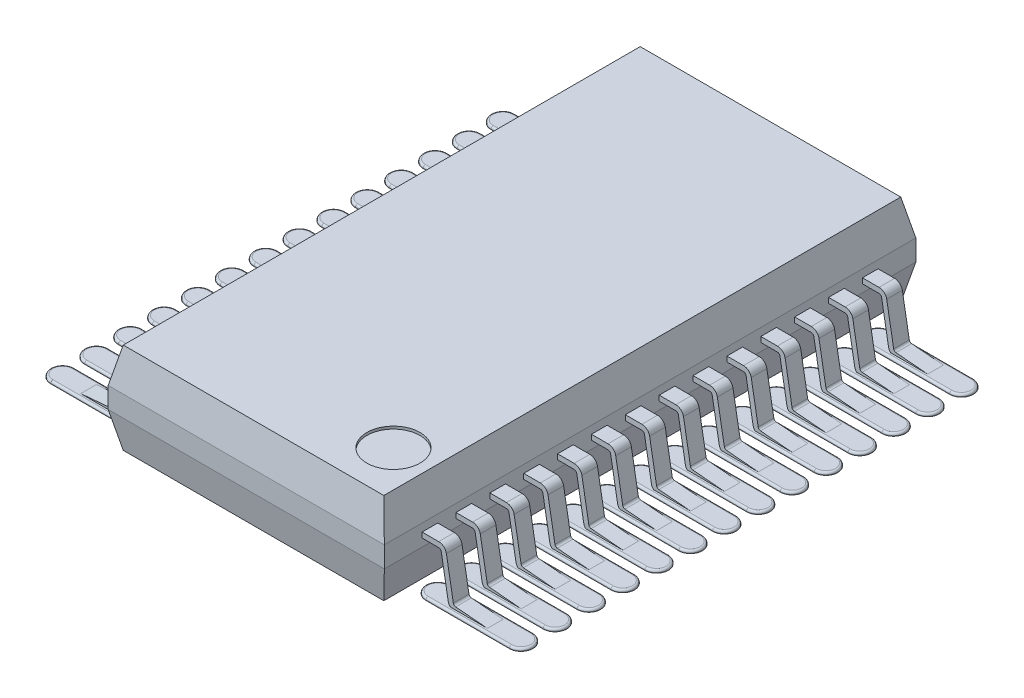
from build123d import *

# Parameters (mm, degrees)
BOSS_EXTRUDE1_DEPTH     = 5.1
CUT_EXTRUDE2_DEPTH      = 7.037797612
CUT_EXTRUDE2_DEPTH_BACK = 7.037797612
EXTRUDE_THIN1_DEPTH     = 0.15
BOSS_EXTRUDE2_DEPTH     = 0.05
FILLET1_R               = 0.04
LPATTERN1_COUNT         = 14
LPATTERN1_PITCH         = 0.65
FILLET1_OF_LPATTERN1_R  = 0.04
SKETCH3_R               = 0.51
CUT_EXTRUDE1_DEPTH      = 0.05


with BuildPart() as part:
    # Sketch1 → Boss-Extrude1 (new, symmetric)
    with BuildSketch(Plane.XY):
        Polygon((-2.5, 1.85), (2.5, 1.85), (2.65, 1.175), (2.65, 0.775), (2.5, 0.1), (-2.5, 0.1), (-2.65, 0.775), (-2.65, 1.175), align=None)
    extrude(amount=BOSS_EXTRUDE1_DEPTH, both=True)

    # Sketch4 → Cut-Extrude2 (cut, two sides)
    with BuildSketch(Plane(origin=(0, 0, 0), x_dir=(0, 0, -1), z_dir=(1, 0, 0))) as cut_extrude2_sk:
        Polygon((-4.96, 1.85), (-5.1, 1.175), (-5.1, 0.775), (-4.96, 0.1), (-5.16, 0.1), (-5.16, 1.85), align=None)
        Polygon((5.1, 1.175), (4.96, 1.85), (5.16, 1.85), (5.16, 0.1), (4.96, 0.1), (5.1, 0.775), align=None)
    extrude(amount=CUT_EXTRUDE2_DEPTH, mode=Mode.SUBTRACT)
    extrude(cut_extrude2_sk.sketch, amount=-CUT_EXTRUDE2_DEPTH_BACK, mode=Mode.SUBTRACT)

    # Sketch2 → Extrude-Thin1 (add, symmetric)
    with BuildSketch(Plane.XY.offset(4.225)):
        with BuildLine():
            Line((-3.895642213, -0.049809735), (-3.285407414, 0.003578892))
            ThreePointArc((-3.285407414, 0.003578892), (-3.197142244, 0.042416496), (-3.150759612, 0.12696087))
            Line((-3.150759612, 0.12696087), (-3.017329188, 0.883682409))
            ThreePointArc((-3.017329188, 0.883682409), (-3.000228181, 0.913302222), (-2.968088801, 0.925))
            Line((-2.968088801, 0.925), (2.968088801, 0.925))
            ThreePointArc((2.968088801, 0.925), (3.000228181, 0.913302222), (3.017329188, 0.883682409))
            Line((3.017329188, 0.883682409), (3.150759612, 0.12696087))
            ThreePointArc((3.150759612, 0.12696087), (3.197142244, 0.042416496), (3.285407414, 0.003578892))
            Line((3.285407414, 0.003578892), (3.895642213, -0.049809735))
            Line((3.895642213, -0.049809735), (3.904357787, 0.049809735))
            Line((3.904357787, 0.049809735), (3.294122988, 0.103198362))
            ThreePointArc((3.294122988, 0.103198362), (3.264701265, 0.11614423), (3.249240388, 0.144325688))
            Line((3.249240388, 0.144325688), (3.115809963, 0.901047227))
            ThreePointArc((3.115809963, 0.901047227), (3.064506942, 0.989906666), (2.968088801, 1.025))
            Line((2.968088801, 1.025), (-2.968088801, 1.025))
            ThreePointArc((-2.968088801, 1.025), (-3.064506942, 0.989906666), (-3.115809963, 0.901047227))
            Line((-3.115809963, 0.901047227), (-3.249240388, 0.144325688))
            ThreePointArc((-3.249240388, 0.144325688), (-3.264701265, 0.11614423), (-3.294122988, 0.103198362))
            Line((-3.294122988, 0.103198362), (-3.904357787, 0.049809735))
            Line((-3.904357787, 0.049809735), (-3.895642213, -0.049809735))
        make_face()
    extrude_thin1 = extrude(amount=EXTRUDE_THIN1_DEPTH, both=True)

    # Sketch5 → Boss-Extrude2 (add)
    with BuildSketch(Plane(origin=(0, 0, 0), x_dir=(1, 0, 0), z_dir=(0, 1, 0))):
        with BuildLine():
            Line((-2.8, -4.45), (-4.4, -4.45))
            ThreePointArc((-4.4, -4.45), (-4.625, -4.225), (-4.4, -4))
            Line((-4.4, -4), (-2.8, -4))
            ThreePointArc((-2.8, -4), (-2.575, -4.225), (-2.8, -4.45))
        make_face()
        with BuildLine():
            Line((2.8, -4), (4.4, -4))
            ThreePointArc((4.4, -4), (4.625, -4.225), (4.4, -4.45))
            Line((4.4, -4.45), (2.8, -4.45))
            ThreePointArc((2.8, -4.45), (2.575, -4.225), (2.8, -4))
        make_face()
    boss_extrude2 = extrude(amount=BOSS_EXTRUDE2_DEPTH)

    # Fillet1
    fillet1_edges = [part.edges().sort_by_distance(p)[0] for p in [
        (-2.575, 0.05, 4.225),
        (-3.6, 0.05, 4),
        (-4.625, 0.05, 4.225),
        (-3.6, 0.05, 4.45),
        (2.575, 0.05, 4.225),
        (3.6, 0.05, 4.45),
        (4.625, 0.05, 4.225),
        (3.6, 0.05, 4),
    ]]
    fillet(fillet1_edges, radius=FILLET1_R)

    # LPattern1: Extrude-Thin1, Boss-Extrude2 ×14
    with Locations(*[(0, 0, -i * LPATTERN1_PITCH) for i in range(1, LPATTERN1_COUNT)]):
        add(extrude_thin1)
        add(boss_extrude2)

    # Fillet1 of LPattern1
    fillet1_of_lpattern1_edges = [part.edges().sort_by_distance(p)[0] for p in [
        (-2.575, 0.05, 3.575),
        (-3.6, 0.05, 3.35),
        (-4.625, 0.05, 3.575),
        (-3.6, 0.05, 3.8),
        (2.575, 0.05, 3.575),
        (3.6, 0.05, 3.8),
        (4.625, 0.05, 3.575),
        (3.6, 0.05, 3.35),
        (-2.575, 0.05, 2.925),
        (-3.6, 0.05, 2.7),
        (-4.625, 0.05, 2.925),
        (-3.6, 0.05, 3.15),
        (2.575, 0.05, 2.925),
        (3.6, 0.05, 3.15),
        (4.625, 0.05, 2.925),
        (3.6, 0.05, 2.7),
        (-2.575, 0.05, 2.275),
        (-3.6, 0.05, 2.05),
        (-4.625, 0.05, 2.275),
        (-3.6, 0.05, 2.5),
        (2.575, 0.05, 2.275),
        (3.6, 0.05, 2.5),
        (4.625, 0.05, 2.275),
        (3.6, 0.05, 2.05),
        (-2.575, 0.05, 1.625),
        (-3.6, 0.05, 1.4),
        (-4.625, 0.05, 1.625),
        (-3.6, 0.05, 1.85),
        (2.575, 0.05, 1.625),
        (3.6, 0.05, 1.85),
        (4.625, 0.05, 1.625),
        (3.6, 0.05, 1.4),
        (-2.575, 0.05, 0.975),
        (-3.6, 0.05, 0.75),
        (-4.625, 0.05, 0.975),
        (-3.6, 0.05, 1.2),
        (2.575, 0.05, 0.975),
        (3.6, 0.05, 1.2),
        (4.625, 0.05, 0.975),
        (3.6, 0.05, 0.75),
        (-2.575, 0.05, 0.325),
        (-3.6, 0.05, 0.1),
        (-4.625, 0.05, 0.325),
        (-3.6, 0.05, 0.55),
        (2.575, 0.05, 0.325),
        (3.6, 0.05, 0.55),
        (4.625, 0.05, 0.325),
        (3.6, 0.05, 0.1),
        (-2.575, 0.05, -0.325),
        (-3.6, 0.05, -0.55),
        (-4.625, 0.05, -0.325),
        (-3.6, 0.05, -0.1),
        (2.575, 0.05, -0.325),
        (3.6, 0.05, -0.1),
        (4.625, 0.05, -0.325),
        (3.6, 0.05, -0.55),
        (-2.575, 0.05, -0.975),
        (-3.6, 0.05, -1.2),
        (-4.625, 0.05, -0.975),
        (-3.6, 0.05, -0.75),
        (2.575, 0.05, -0.975),
        (3.6, 0.05, -0.75),
        (4.625, 0.05, -0.975),
        (3.6, 0.05, -1.2),
        (-2.575, 0.05, -1.625),
        (-3.6, 0.05, -1.85),
        (-4.625, 0.05, -1.625),
        (-3.6, 0.05, -1.4),
        (2.575, 0.05, -1.625),
        (3.6, 0.05, -1.4),
        (4.625, 0.05, -1.625),
        (3.6, 0.05, -1.85),
        (-2.575, 0.05, -2.275),
        (-3.6, 0.05, -2.5),
        (-4.625, 0.05, -2.275),
        (-3.6, 0.05, -2.05),
        (2.575, 0.05, -2.275),
        (3.6, 0.05, -2.05),
        (4.625, 0.05, -2.275),
        (3.6, 0.05, -2.5),
        (-2.575, 0.05, -2.925),
        (-3.6, 0.05, -3.15),
        (-4.625, 0.05, -2.925),
        (-3.6, 0.05, -2.7),
        (2.575, 0.05, -2.925),
        (3.6, 0.05, -2.7),
        (4.625, 0.05, -2.925),
        (3.6, 0.05, -3.15),
        (-2.575, 0.05, -3.575),
        (-3.6, 0.05, -3.8),
        (-4.625, 0.05, -3.575),
        (-3.6, 0.05, -3.35),
        (2.575, 0.05, -3.575),
        (3.6, 0.05, -3.35),
        (4.625, 0.05, -3.575),
        (3.6, 0.05, -3.8),
        (-2.575, 0.05, -4.225),
        (-3.6, 0.05, -4.45),
        (-4.625, 0.05, -4.225),
        (-3.6, 0.05, -4),
        (2.575, 0.05, -4.225),
        (3.6, 0.05, -4),
        (4.625, 0.05, -4.225),
        (3.6, 0.05, -4.45),
    ]]
    fillet(fillet1_of_lpattern1_edges, radius=FILLET1_OF_LPATTERN1_R)

    # Sketch3 → Cut-Extrude1 (cut)
    with BuildSketch(Plane(origin=(0, 1.85, 0), x_dir=(-1, 0, 0), z_dir=(0, 1, 0))):
        with Locations((-1.8, 4.075)):
            Circle(SKETCH3_R)
    extrude(amount=-CUT_EXTRUDE1_DEPTH, mode=Mode.SUBTRACT)


solid = part.part
